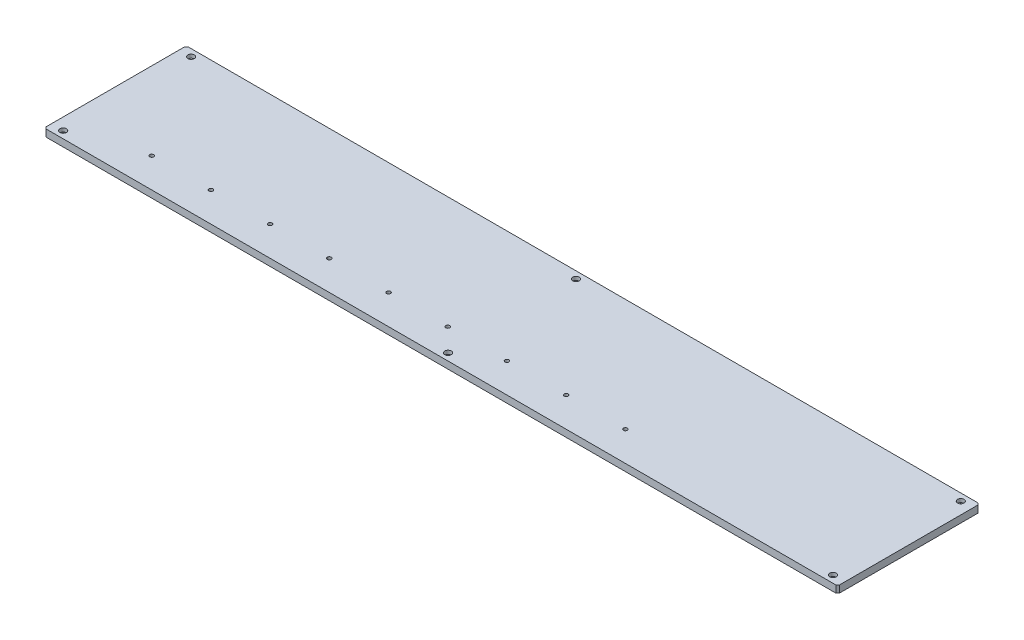
from build123d import *

# Parameters (mm, degrees)
SKETCH1_W                                       = 1340
SKETCH1_H                                       = 240
BOSS_EXTRUDE1_DEPTH                             = 12
CBORE_FOR_M6_SOCKET_HEAD_CAP_SCREW1_D           = 6.6
CBORE_FOR_M6_SOCKET_HEAD_CAP_SCREW1_CBORE_D     = 11
CBORE_FOR_M6_SOCKET_HEAD_CAP_SCREW1_CBORE_DEPTH = 6
CBORE_FOR_M6_SOCKET_HEAD_CAP_SCREW2_D           = 6.6
CBORE_FOR_M6_SOCKET_HEAD_CAP_SCREW2_CBORE_D     = 11
CBORE_FOR_M6_SOCKET_HEAD_CAP_SCREW2_CBORE_DEPTH = 6
CHAMFER1_SIZE                                   = 3


with BuildPart() as part:
    # Sketch1 → Boss-Extrude1 (new body)
    with BuildSketch(Plane(origin=(0, 0, 0), x_dir=(1, 0, 0), z_dir=(0, 1, 0))):
        with Locations((670, 0)):
            Rectangle(SKETCH1_W, SKETCH1_H)
    extrude(amount=BOSS_EXTRUDE1_DEPTH)

    # CBORE for M6 Socket Head Cap Screw1 (through all)
    with Locations(Plane(origin=(0, 12, 0), x_dir=(-1, 0, 0), z_dir=(0, 1, 0))):
        with Locations((-20, 108), (-20, -108), (-670, 108), (-670, -108), (-1320, 108), (-1320, -108)):
            CounterBoreHole(CBORE_FOR_M6_SOCKET_HEAD_CAP_SCREW1_D / 2, CBORE_FOR_M6_SOCKET_HEAD_CAP_SCREW1_CBORE_D / 2, CBORE_FOR_M6_SOCKET_HEAD_CAP_SCREW1_CBORE_DEPTH)

    # CBORE for M6 Socket Head Cap Screw2 (through all)
    with Locations(Plane.XZ):
        with Locations((131.5, 70), (231.5, 70), (331.5, 70), (431.5, 70), (531.5, 70), (631.5, 70), (731.5, 70), (831.5, 70), (931.5, 70)):
            CounterBoreHole(CBORE_FOR_M6_SOCKET_HEAD_CAP_SCREW2_D / 2, CBORE_FOR_M6_SOCKET_HEAD_CAP_SCREW2_CBORE_D / 2, CBORE_FOR_M6_SOCKET_HEAD_CAP_SCREW2_CBORE_DEPTH)

    # Chamfer1
    chamfer1_edges = [part.edges().sort_by_distance(p)[0] for p in [
        (0, 6, -120),
        (1340, 6, -120),
        (1340, 6, 120),
        (0, 6, 120),
    ]]
    chamfer(chamfer1_edges, length=CHAMFER1_SIZE)


solid = part.part
